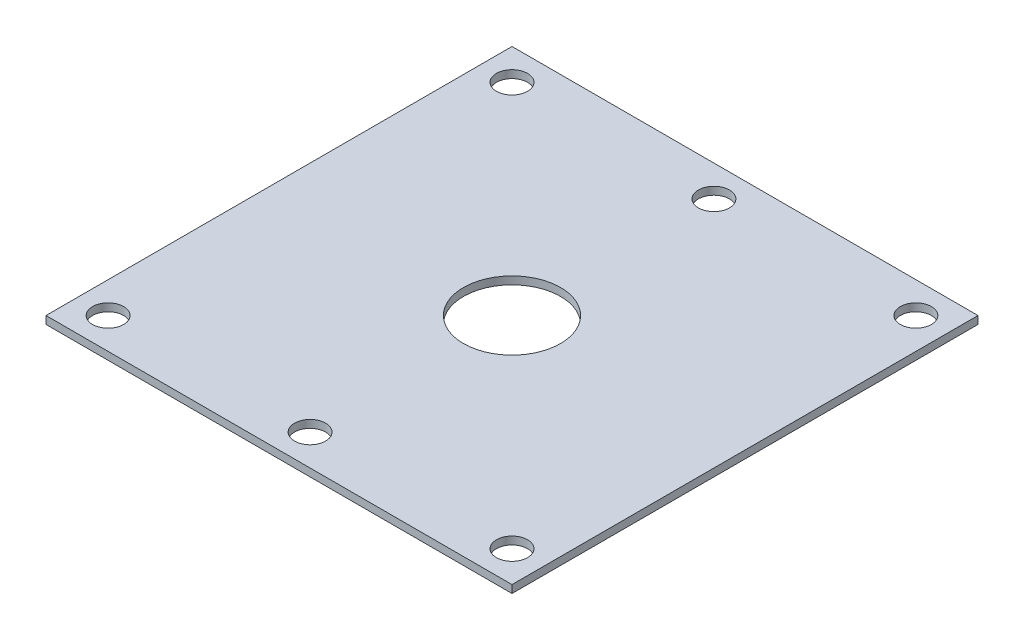
from build123d import *

# Parameters (mm, degrees)
SKETCH1_W           = 60
SKETCH1_H           = 60
BOSS_EXTRUDE1_DEPTH = 1
SKETCH2_R           = 2
CUT_EXTRUDE1_DEPTH  = 2
SKETCH4_R           = 6.25
CUT_EXTRUDE3_DEPTH  = 10


with BuildPart() as part:
    # Sketch1 → Boss-Extrude1 (new body)
    with BuildSketch(Plane(origin=(0, 0, 0), x_dir=(1, 0, 0), z_dir=(0, 1, 0))):
        Rectangle(SKETCH1_W, SKETCH1_H)
    extrude(amount=BOSS_EXTRUDE1_DEPTH)

    # Sketch2 → Cut-Extrude1 (cut, through all)
    with BuildSketch(Plane(origin=(0, 1, 0), x_dir=(1, 0, 0), z_dir=(0, 1, 0))):
        with Locations((-26, 26)):
            Circle(SKETCH2_R)
        with Locations((0, 26)):
            Circle(SKETCH2_R)
        with Locations((26, 26)):
            Circle(SKETCH2_R)
        with Locations((26, -26)):
            Circle(SKETCH2_R)
        with Locations((0, -26)):
            Circle(SKETCH2_R)
        with Locations((-26, -26)):
            Circle(SKETCH2_R)
    extrude(amount=-CUT_EXTRUDE1_DEPTH, mode=Mode.SUBTRACT)

    # Sketch4 → Cut-Extrude3 (cut)
    with BuildSketch(Plane(origin=(0, 1, 0), x_dir=(1, 0, 0), z_dir=(0, 1, 0))):
        Circle(SKETCH4_R)
    extrude(amount=-CUT_EXTRUDE3_DEPTH, mode=Mode.SUBTRACT)


solid = part.part
